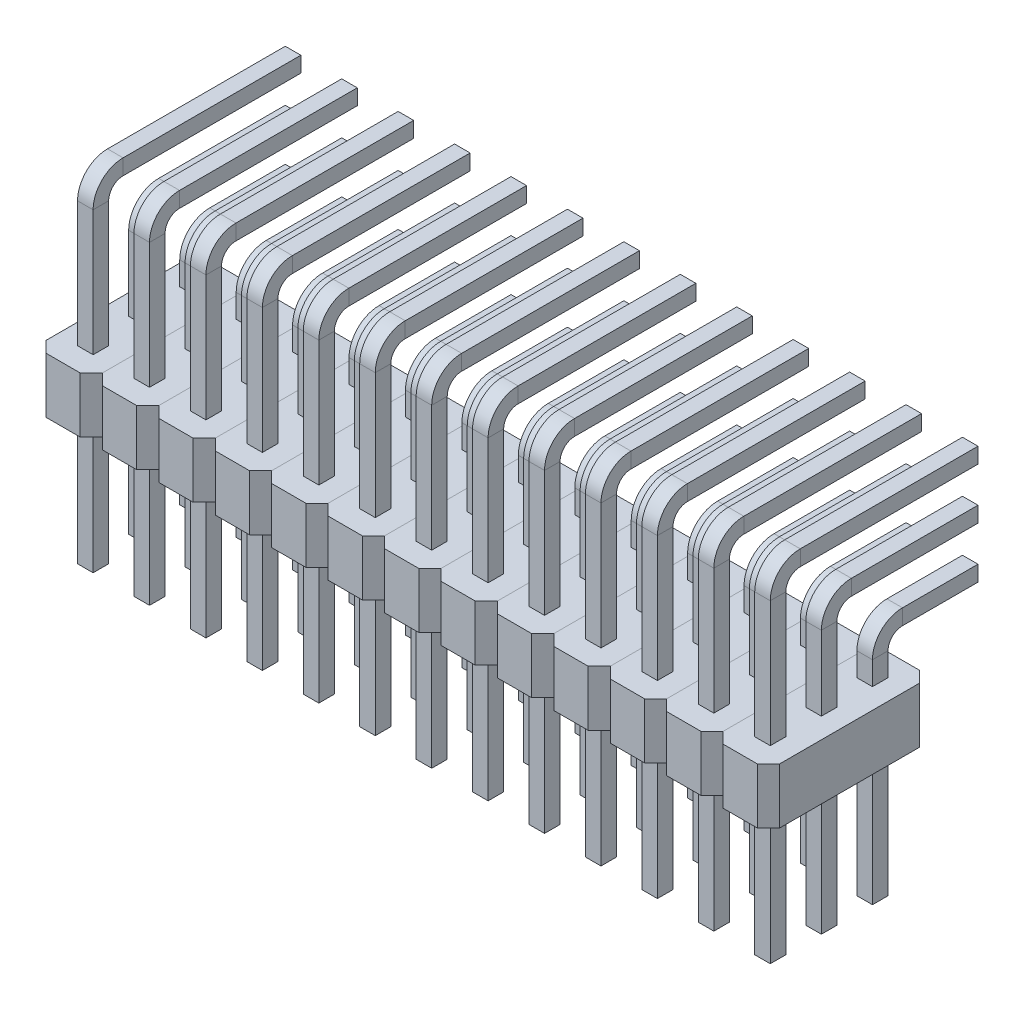
from build123d import *

# Parameters (mm, degrees)
SKETCH1_W           = 0.7
SKETCH1_H           = 0.7
SKETCH1_5_W         = 0.7
SKETCH1_5_H         = 0.7
SKETCH1_6_W         = 0.7
SKETCH1_6_H         = 0.7
SKETCH1_7_W         = 2.54
SKETCH1_7_H         = 7.3
SKETCH1_7_W_2       = 0.7
SKETCH1_7_H_2       = 0.7
BOSS_EXTRUDE1_DEPTH = 2.5
CHAMFER1_SIZE       = 0.5
LPATTERN1_COUNT     = 13
LPATTERN1_PITCH     = 2.54


with BuildPart() as part:
    # Sweep3: sweep along a path in Sketch2
    with BuildLine(Plane(origin=(1.25, 0, 0), x_dir=(0, 0, -1), z_dir=(1, 0, 0))) as sweep3_path:
        Line((-5.95, -6), (-5.95, 8.15))
        ThreePointArc((-5.95, 8.15), (-5.657106781, 8.857106781), (-4.95, 9.15))
        Line((-4.95, 9.15), (3.05, 9.15))
    # Sketch1 → Sweep3 (sweep)
    with BuildSketch(Plane(origin=(0, 0, 0), x_dir=(1, 0, 0), z_dir=(0, 1, 0))):
        with Locations((1.27, -5.95)):
            Rectangle(SKETCH1_W, SKETCH1_H)
    sweep(path=sweep3_path.line)


with BuildPart() as body_2:
    # Sweep4: sweep along a path in Sketch2_6
    with BuildLine(Plane(origin=(1.25, 0, 0), x_dir=(0, 0, -1), z_dir=(1, 0, 0))) as sweep4_path:
        Line((-3.65, -6), (-3.65, 5.85))
        ThreePointArc((-3.65, 5.85), (-3.357106781, 6.557106781), (-2.65, 6.85))
        Line((-2.65, 6.85), (3.05, 6.85))
    # Sketch1_5 → Sweep4 (sweep)
    with BuildSketch(Plane(origin=(0, 0, 0), x_dir=(1, 0, 0), z_dir=(0, 1, 0))):
        with Locations((1.27, -3.65)):
            Rectangle(SKETCH1_5_W, SKETCH1_5_H)
    sweep(path=sweep4_path.line)


with BuildPart() as body_3:
    # Sweep5: sweep along a path in Sketch2_7
    with BuildLine(Plane(origin=(1.25, 0, 0), x_dir=(0, 0, -1), z_dir=(1, 0, 0))) as sweep5_path:
        Line((-1.35, -6), (-1.35, 3.55))
        ThreePointArc((-1.35, 3.55), (-1.057106781, 4.257106781), (-0.35, 4.55))
        Line((-0.35, 4.55), (3.05, 4.55))
    # Sketch1_6 → Sweep5 (sweep)
    with BuildSketch(Plane(origin=(0, 0, 0), x_dir=(1, 0, 0), z_dir=(0, 1, 0))):
        with Locations((1.27, -1.35)):
            Rectangle(SKETCH1_6_W, SKETCH1_6_H)
    sweep(path=sweep5_path.line)


with BuildPart() as body_4:
    # Sketch1_7 → Boss-Extrude1 (new body)
    with BuildSketch(Plane(origin=(0, 0, 0), x_dir=(1, 0, 0), z_dir=(0, 1, 0))):
        with Locations((1.27, -3.65)):
            Rectangle(SKETCH1_7_W, SKETCH1_7_H)
        with Locations((1.27, -1.35)):
            Rectangle(SKETCH1_7_W_2, SKETCH1_7_H_2, mode=Mode.SUBTRACT)
        with Locations((1.27, -5.95)):
            Rectangle(SKETCH1_7_W_2, SKETCH1_7_H_2, mode=Mode.SUBTRACT)
        with Locations((1.27, -3.65)):
            Rectangle(SKETCH1_7_W_2, SKETCH1_7_H_2, mode=Mode.SUBTRACT)
    extrude(amount=BOSS_EXTRUDE1_DEPTH)

    # Chamfer1
    chamfer1_edges = [body_4.edges().sort_by_distance(p)[0] for p in [
        (2.54, 1.25, 7.3),
        (0, 1.25, 7.3),
        (0, 1.25, 0),
        (2.54, 1.25, 0),
    ]]
    chamfer(chamfer1_edges, length=CHAMFER1_SIZE)


with BuildPart() as lpattern1_1:
    # LPattern1: pattern copy
    add(body_4.part.moved(Location(Vector(1, 0, 0) * (1 * LPATTERN1_PITCH))))


with BuildPart() as lpattern1_2:
    # LPattern1: pattern copy
    add(body_4.part.moved(Location(Vector(1, 0, 0) * (2 * LPATTERN1_PITCH))))


with BuildPart() as lpattern1_3:
    # LPattern1: pattern copy
    add(body_4.part.moved(Location(Vector(1, 0, 0) * (3 * LPATTERN1_PITCH))))


with BuildPart() as lpattern1_4:
    # LPattern1: pattern copy
    add(body_4.part.moved(Location(Vector(1, 0, 0) * (4 * LPATTERN1_PITCH))))


with BuildPart() as lpattern1_5:
    # LPattern1: pattern copy
    add(body_4.part.moved(Location(Vector(1, 0, 0) * (5 * LPATTERN1_PITCH))))


with BuildPart() as lpattern1_6:
    # LPattern1: pattern copy
    add(body_4.part.moved(Location(Vector(1, 0, 0) * (6 * LPATTERN1_PITCH))))


with BuildPart() as lpattern1_7:
    # LPattern1: pattern copy
    add(body_4.part.moved(Location(Vector(1, 0, 0) * (7 * LPATTERN1_PITCH))))


with BuildPart() as lpattern1_8:
    # LPattern1: pattern copy
    add(body_4.part.moved(Location(Vector(1, 0, 0) * (8 * LPATTERN1_PITCH))))


with BuildPart() as lpattern1_9:
    # LPattern1: pattern copy
    add(body_4.part.moved(Location(Vector(1, 0, 0) * (9 * LPATTERN1_PITCH))))


with BuildPart() as lpattern1_10:
    # LPattern1: pattern copy
    add(body_4.part.moved(Location(Vector(1, 0, 0) * (10 * LPATTERN1_PITCH))))


with BuildPart() as lpattern1_11:
    # LPattern1: pattern copy
    add(body_4.part.moved(Location(Vector(1, 0, 0) * (11 * LPATTERN1_PITCH))))


with BuildPart() as lpattern1_12:
    # LPattern1: pattern copy
    add(body_4.part.moved(Location(Vector(1, 0, 0) * (12 * LPATTERN1_PITCH))))


with BuildPart() as lpattern1_13:
    # LPattern1: pattern copy
    add(body_3.part.moved(Location(Vector(1, 0, 0) * (1 * LPATTERN1_PITCH))))


with BuildPart() as lpattern1_14:
    # LPattern1: pattern copy
    add(body_3.part.moved(Location(Vector(1, 0, 0) * (2 * LPATTERN1_PITCH))))


with BuildPart() as lpattern1_15:
    # LPattern1: pattern copy
    add(body_3.part.moved(Location(Vector(1, 0, 0) * (3 * LPATTERN1_PITCH))))


with BuildPart() as lpattern1_16:
    # LPattern1: pattern copy
    add(body_3.part.moved(Location(Vector(1, 0, 0) * (4 * LPATTERN1_PITCH))))


with BuildPart() as lpattern1_17:
    # LPattern1: pattern copy
    add(body_3.part.moved(Location(Vector(1, 0, 0) * (5 * LPATTERN1_PITCH))))


with BuildPart() as lpattern1_18:
    # LPattern1: pattern copy
    add(body_3.part.moved(Location(Vector(1, 0, 0) * (6 * LPATTERN1_PITCH))))


with BuildPart() as lpattern1_19:
    # LPattern1: pattern copy
    add(body_3.part.moved(Location(Vector(1, 0, 0) * (7 * LPATTERN1_PITCH))))


with BuildPart() as lpattern1_20:
    # LPattern1: pattern copy
    add(body_3.part.moved(Location(Vector(1, 0, 0) * (8 * LPATTERN1_PITCH))))


with BuildPart() as lpattern1_21:
    # LPattern1: pattern copy
    add(body_3.part.moved(Location(Vector(1, 0, 0) * (9 * LPATTERN1_PITCH))))


with BuildPart() as lpattern1_22:
    # LPattern1: pattern copy
    add(body_3.part.moved(Location(Vector(1, 0, 0) * (10 * LPATTERN1_PITCH))))


with BuildPart() as lpattern1_23:
    # LPattern1: pattern copy
    add(body_3.part.moved(Location(Vector(1, 0, 0) * (11 * LPATTERN1_PITCH))))


with BuildPart() as lpattern1_24:
    # LPattern1: pattern copy
    add(body_3.part.moved(Location(Vector(1, 0, 0) * (12 * LPATTERN1_PITCH))))


with BuildPart() as lpattern1_25:
    # LPattern1: pattern copy
    add(body_2.part.moved(Location(Vector(1, 0, 0) * (1 * LPATTERN1_PITCH))))


with BuildPart() as lpattern1_26:
    # LPattern1: pattern copy
    add(body_2.part.moved(Location(Vector(1, 0, 0) * (2 * LPATTERN1_PITCH))))


with BuildPart() as lpattern1_27:
    # LPattern1: pattern copy
    add(body_2.part.moved(Location(Vector(1, 0, 0) * (3 * LPATTERN1_PITCH))))


with BuildPart() as lpattern1_28:
    # LPattern1: pattern copy
    add(body_2.part.moved(Location(Vector(1, 0, 0) * (4 * LPATTERN1_PITCH))))


with BuildPart() as lpattern1_29:
    # LPattern1: pattern copy
    add(body_2.part.moved(Location(Vector(1, 0, 0) * (5 * LPATTERN1_PITCH))))


with BuildPart() as lpattern1_30:
    # LPattern1: pattern copy
    add(body_2.part.moved(Location(Vector(1, 0, 0) * (6 * LPATTERN1_PITCH))))


with BuildPart() as lpattern1_31:
    # LPattern1: pattern copy
    add(body_2.part.moved(Location(Vector(1, 0, 0) * (7 * LPATTERN1_PITCH))))


with BuildPart() as lpattern1_32:
    # LPattern1: pattern copy
    add(body_2.part.moved(Location(Vector(1, 0, 0) * (8 * LPATTERN1_PITCH))))


with BuildPart() as lpattern1_33:
    # LPattern1: pattern copy
    add(body_2.part.moved(Location(Vector(1, 0, 0) * (9 * LPATTERN1_PITCH))))


with BuildPart() as lpattern1_34:
    # LPattern1: pattern copy
    add(body_2.part.moved(Location(Vector(1, 0, 0) * (10 * LPATTERN1_PITCH))))


with BuildPart() as lpattern1_35:
    # LPattern1: pattern copy
    add(body_2.part.moved(Location(Vector(1, 0, 0) * (11 * LPATTERN1_PITCH))))


with BuildPart() as lpattern1_36:
    # LPattern1: pattern copy
    add(body_2.part.moved(Location(Vector(1, 0, 0) * (12 * LPATTERN1_PITCH))))


with BuildPart() as lpattern1_37:
    # LPattern1: pattern copy
    add(part.part.moved(Location(Vector(1, 0, 0) * (1 * LPATTERN1_PITCH))))


with BuildPart() as lpattern1_38:
    # LPattern1: pattern copy
    add(part.part.moved(Location(Vector(1, 0, 0) * (2 * LPATTERN1_PITCH))))


with BuildPart() as lpattern1_39:
    # LPattern1: pattern copy
    add(part.part.moved(Location(Vector(1, 0, 0) * (3 * LPATTERN1_PITCH))))


with BuildPart() as lpattern1_40:
    # LPattern1: pattern copy
    add(part.part.moved(Location(Vector(1, 0, 0) * (4 * LPATTERN1_PITCH))))


with BuildPart() as lpattern1_41:
    # LPattern1: pattern copy
    add(part.part.moved(Location(Vector(1, 0, 0) * (5 * LPATTERN1_PITCH))))


with BuildPart() as lpattern1_42:
    # LPattern1: pattern copy
    add(part.part.moved(Location(Vector(1, 0, 0) * (6 * LPATTERN1_PITCH))))


with BuildPart() as lpattern1_43:
    # LPattern1: pattern copy
    add(part.part.moved(Location(Vector(1, 0, 0) * (7 * LPATTERN1_PITCH))))


with BuildPart() as lpattern1_44:
    # LPattern1: pattern copy
    add(part.part.moved(Location(Vector(1, 0, 0) * (8 * LPATTERN1_PITCH))))


with BuildPart() as lpattern1_45:
    # LPattern1: pattern copy
    add(part.part.moved(Location(Vector(1, 0, 0) * (9 * LPATTERN1_PITCH))))


with BuildPart() as lpattern1_46:
    # LPattern1: pattern copy
    add(part.part.moved(Location(Vector(1, 0, 0) * (10 * LPATTERN1_PITCH))))


with BuildPart() as lpattern1_47:
    # LPattern1: pattern copy
    add(part.part.moved(Location(Vector(1, 0, 0) * (11 * LPATTERN1_PITCH))))


with BuildPart() as lpattern1_48:
    # LPattern1: pattern copy
    add(part.part.moved(Location(Vector(1, 0, 0) * (12 * LPATTERN1_PITCH))))


solid = Compound([part.part, body_2.part, body_3.part, body_4.part, lpattern1_1.part, lpattern1_2.part, lpattern1_3.part, lpattern1_4.part, lpattern1_5.part, lpattern1_6.part, lpattern1_7.part, lpattern1_8.part, lpattern1_9.part, lpattern1_10.part, lpattern1_11.part, lpattern1_12.part, lpattern1_13.part, lpattern1_14.part, lpattern1_15.part, lpattern1_16.part, lpattern1_17.part, lpattern1_18.part, lpattern1_19.part, lpattern1_20.part, lpattern1_21.part, lpattern1_22.part, lpattern1_23.part, lpattern1_24.part, lpattern1_25.part, lpattern1_26.part, lpattern1_27.part, lpattern1_28.part, lpattern1_29.part, lpattern1_30.part, lpattern1_31.part, lpattern1_32.part, lpattern1_33.part, lpattern1_34.part, lpattern1_35.part, lpattern1_36.part, lpattern1_37.part, lpattern1_38.part, lpattern1_39.part, lpattern1_40.part, lpattern1_41.part, lpattern1_42.part, lpattern1_43.part, lpattern1_44.part, lpattern1_45.part, lpattern1_46.part, lpattern1_47.part, lpattern1_48.part])
